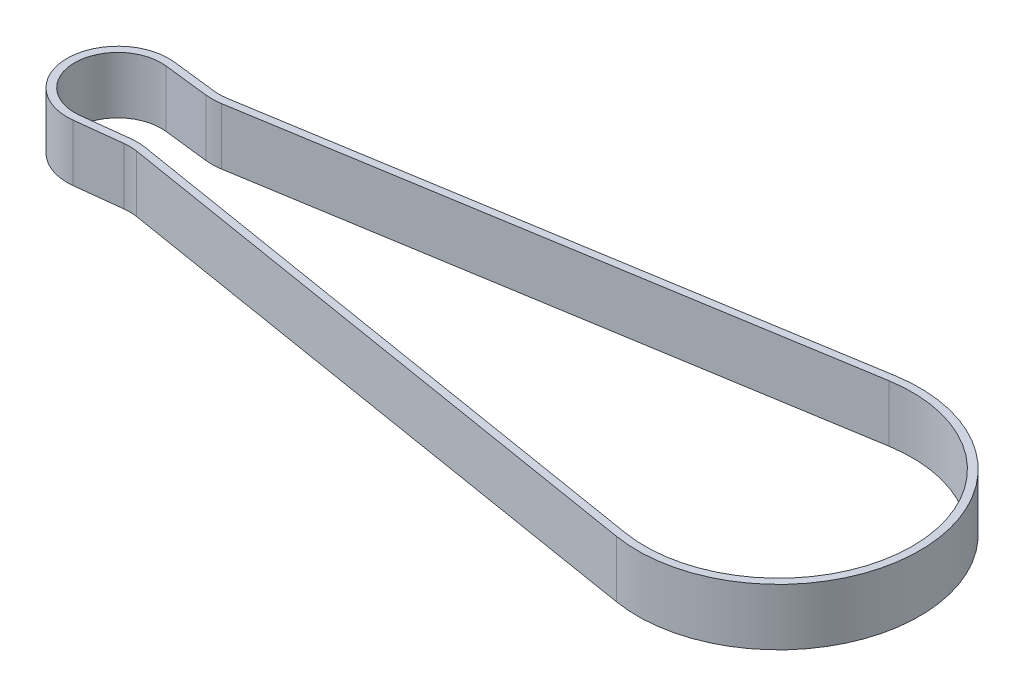
from build123d import *

# Parameters (mm, degrees)
LINEAR_AUSTRAGEN_D_NN1_DEPTH      = 3
LINEAR_AUSTRAGEN_D_NN1_DEPTH_BACK = 3


with BuildPart() as part:
    # Skizze1 → Linear-Austragen-Dünn1 (new body, two sides)
    with BuildSketch(Plane(origin=(0, 0, 0), x_dir=(1, 0, 0), z_dir=(0, 1, 0))) as linear_austragen_d_nn1_sk:
        with BuildLine():
            Line((5.425321809, 4.783135297), (0.617779056, 5.339379556))
            ThreePointArc((0.617779056, 5.339379556), (-5.375, 0), (0.617779056, -5.339379556))
            Line((0.617779056, -5.339379556), (5.425321809, -4.783135297))
            ThreePointArc((5.425321809, -4.783135297), (6.11685444, -4.751365683), (6.806147081, -4.815415227))
            Line((6.806147081, -4.815415227), (67.493650964, -14.729735548))
            ThreePointArc((67.493650964, -14.729735548), (84.825, 0), (67.493650964, 14.729735548))
            Line((67.493650964, 14.729735548), (6.806147081, 4.815415227))
            ThreePointArc((6.806147081, 4.815415227), (6.11685444, 4.751365683), (5.425321809, 4.783135297))
        make_face()
        with BuildLine():
            Line((5.333373298, 3.988436945), (0.525830545, 4.544681203))
            ThreePointArc((0.525830545, 4.544681203), (-4.575, 0), (0.525830545, -4.544681203))
            Line((0.525830545, -4.544681203), (5.333373298, -3.988436945))
            ThreePointArc((5.333373298, -3.988436945), (6.135551151, -3.951584192), (6.935130614, -4.025881663))
            Line((6.935130614, -4.025881663), (67.622634497, -13.940201984))
            ThreePointArc((67.622634497, -13.940201984), (84.025, 0), (67.622634497, 13.940201984))
            Line((67.622634497, 13.940201984), (6.935130614, 4.025881663))
            ThreePointArc((6.935130614, 4.025881663), (6.135551151, 3.951584192), (5.333373298, 3.988436945))
        make_face(mode=Mode.SUBTRACT)
    extrude(amount=LINEAR_AUSTRAGEN_D_NN1_DEPTH)
    extrude(linear_austragen_d_nn1_sk.sketch, amount=-LINEAR_AUSTRAGEN_D_NN1_DEPTH_BACK)


solid = part.part
